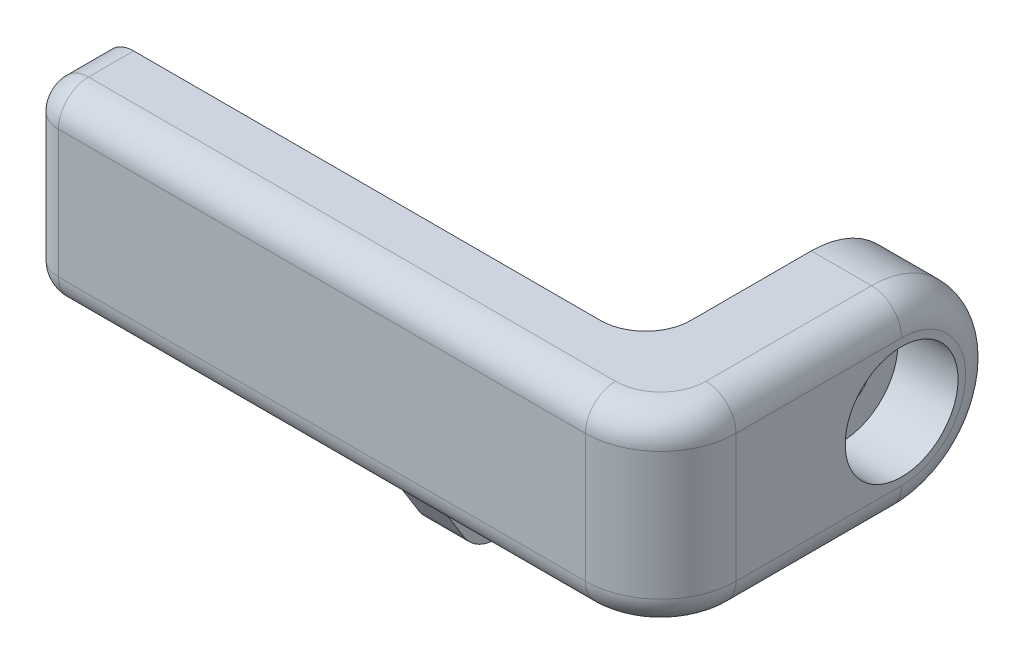
from build123d import *

# Parameters (mm, degrees)
SKETCH1_R           = 12.5
SKETCH1_R_2         = 7.5
BOSS_EXTRUDE1_DEPTH = 12
SKETCH1_3_R         = 7.5
SKETCH1_3_R_2       = 4
BOSS_EXTRUDE2_DEPTH = 4
SKETCH2_W           = 12
SKETCH2_H           = 25
BOSS_EXTRUDE3_DEPTH = 32
CUT_EXTRUDE1_DEPTH  = 8
CUT_EXTRUDE2_DEPTH  = 13
SKETCH4_W           = 10
SKETCH4_H           = 25
BOSS_EXTRUDE4_DEPTH = 72
FILLET1_R           = 6
FILLET2_R           = 10
FILLET3_R           = 4
SKETCH5_W           = 6
SKETCH5_H           = 30.078064569
BOSS_EXTRUDE5_DEPTH = 35
CUT_EXTRUDE3_REACH  = 43
SKETCH7_W           = 6
SKETCH7_H           = 17.578064569
BOSS_EXTRUDE6_DEPTH = 6
CUT_EXTRUDE4_REACH  = 43
FILLET4_R           = 5


with BuildPart() as part:
    # Sketch1 → Boss-Extrude1 (new body)
    with BuildSketch(Plane(origin=(0, 0, 0), x_dir=(0, 0, -1), z_dir=(1, 0, 0))):
        Circle(SKETCH1_R)
        Circle(SKETCH1_R_2, mode=Mode.SUBTRACT)
    extrude(amount=BOSS_EXTRUDE1_DEPTH)

    # Sketch1_3 → Boss-Extrude2 (add)
    with BuildSketch(Plane(origin=(0, 0, 0), x_dir=(0, 0, -1), z_dir=(1, 0, 0))):
        Circle(SKETCH1_3_R)
        Circle(SKETCH1_3_R_2, mode=Mode.SUBTRACT)
    extrude(amount=BOSS_EXTRUDE2_DEPTH)

    # Sketch2 → Boss-Extrude3 (add)
    with BuildSketch(Plane.XY):
        with Locations((6, 0)):
            Rectangle(SKETCH2_W, SKETCH2_H)
    extrude(amount=BOSS_EXTRUDE3_DEPTH)

    # Sketch3 → Cut-Extrude1 (cut)
    with BuildSketch(Plane(origin=(12, 0, -12), x_dir=(0, 0, 1), z_dir=(-1, 0, 0))):
        with BuildLine():
            ThreePointArc((12, 4), (14.828427125, 2.828427125), (16, 0))
            ThreePointArc((16, 0), (14.828427125, -2.828427125), (12, -4))
            Line((12, -4), (12, -7.5))
            ThreePointArc((12, -7.5), (17.303300859, -5.303300859), (19.5, 0))
            ThreePointArc((19.5, 0), (17.303300859, 5.303300859), (12, 7.5))
            Line((12, 7.5), (12, 4))
        make_face()
        with BuildLine():
            ThreePointArc((12, -4), (8, 0), (12, 4))
            Line((12, 4), (12, 7.5))
            ThreePointArc((12, 7.5), (4.5, 0), (12, -7.5))
            Line((12, -7.5), (12, -4))
        make_face()
    extrude(amount=CUT_EXTRUDE1_DEPTH, mode=Mode.SUBTRACT)

    # Sketch3_6 → Cut-Extrude2 (cut, through all)
    with BuildSketch(Plane(origin=(12, 0, -12), x_dir=(0, 0, 1), z_dir=(-1, 0, 0))):
        with BuildLine():
            ThreePointArc((12, -4), (14.828427125, -2.828427125), (16, 0))
            ThreePointArc((16, 0), (14.828427125, 2.828427125), (12, 4))
            Line((12, 4), (12, -4))
        make_face()
        with BuildLine():
            Line((12, -4), (12, 4))
            ThreePointArc((12, 4), (8, 0), (12, -4))
        make_face()
    extrude(amount=CUT_EXTRUDE2_DEPTH, mode=Mode.SUBTRACT)

    # Sketch4 → Boss-Extrude4 (add)
    with BuildSketch(Plane.ZY):
        with Locations((27, 0)):
            Rectangle(SKETCH4_W, SKETCH4_H)
    extrude(amount=BOSS_EXTRUDE4_DEPTH)

    # Fillet1
    fillet1_edges = [part.edges().sort_by_distance(p)[0] for p in [
        (0, 0, 22),
    ]]
    fillet(fillet1_edges, radius=FILLET1_R)

    # Fillet2
    fillet2_edges = [part.edges().sort_by_distance(p)[0] for p in [
        (12, 0, 32),
    ]]
    fillet(fillet2_edges, radius=FILLET2_R)

    # Fillet3
    fillet3_edges = [part.edges().sort_by_distance(p)[0] for p in [
        (9.071067812, -12.5, 29.071067812),
        (12, 0, -12.5),
        (-36, -12.5, 32),
        (-72, 0, 32),
        (-72, 12.5, 27),
        (-72, -12.5, 27),
        (-36, 12.5, 32),
        (12, 12.5, 11),
        (9.071067812, 12.5, 29.071067812),
        (12, -12.5, 11),
    ]]
    fillet(fillet3_edges, radius=FILLET3_R)

    # Sketch5 → Boss-Extrude5 (add)
    with BuildSketch(Plane(origin=(0, 0, 22), x_dir=(-1, 0, 0), z_dir=(0, 0, -1))):
        with Locations((26, -15.039032285)):
            Rectangle(SKETCH5_W, SKETCH5_H)
    extrude(amount=BOSS_EXTRUDE5_DEPTH)

    # Sketch6 → Cut-Extrude3 (cut, up to next)
    with BuildSketch(Plane.ZY.offset(29), mode=Mode.PRIVATE) as cut_extrude3_sk1:
        Polygon((-4.627390911, -30.078064569), (14.060102478, 0), (-13, 0), (-13, -30.078064569), align=None)
    cut_extrude3_tool1 = extrude(cut_extrude3_sk1.sketch, amount=-CUT_EXTRUDE3_REACH, mode=Mode.PRIVATE) & part.part
    add(cut_extrude3_tool1.solids().sort_by_distance((-29, -12.395131, -3.320494))[0], mode=Mode.SUBTRACT)

    # Sketch7 → Boss-Extrude6 (add)
    with BuildSketch(Plane.XY.offset(22)):
        with Locations((-26, -21.289032285)):
            Rectangle(SKETCH7_W, SKETCH7_H)
    extrude(amount=BOSS_EXTRUDE6_DEPTH)

    # Sketch8 → Cut-Extrude4 (cut, up to next)
    with BuildSketch(Plane.ZY.offset(29), mode=Mode.PRIVATE) as cut_extrude4_sk1:
        Polygon((28, -12.5), (21.643434009, -22.731077991), (-0.062710135, -22.731077991), (-4.627390911, -30.078064569), (28, -30.078064569), align=None)
    cut_extrude4_tool1 = extrude(cut_extrude4_sk1.sketch, amount=-CUT_EXTRUDE4_REACH, mode=Mode.PRIVATE) & part.part
    add(cut_extrude4_tool1.solids().sort_by_distance((-29, -25.583256, 14.464083))[0], mode=Mode.SUBTRACT)

    # Fillet4
    fillet4_edges = [part.edges().sort_by_distance(p)[0] for p in [
        (-26, 0, 14.060102478),
        (-26, -22.731077991, -0.062710135),
        (-26, -22.731077991, 21.643434009),
    ]]
    fillet(fillet4_edges, radius=FILLET4_R)


solid = part.part
